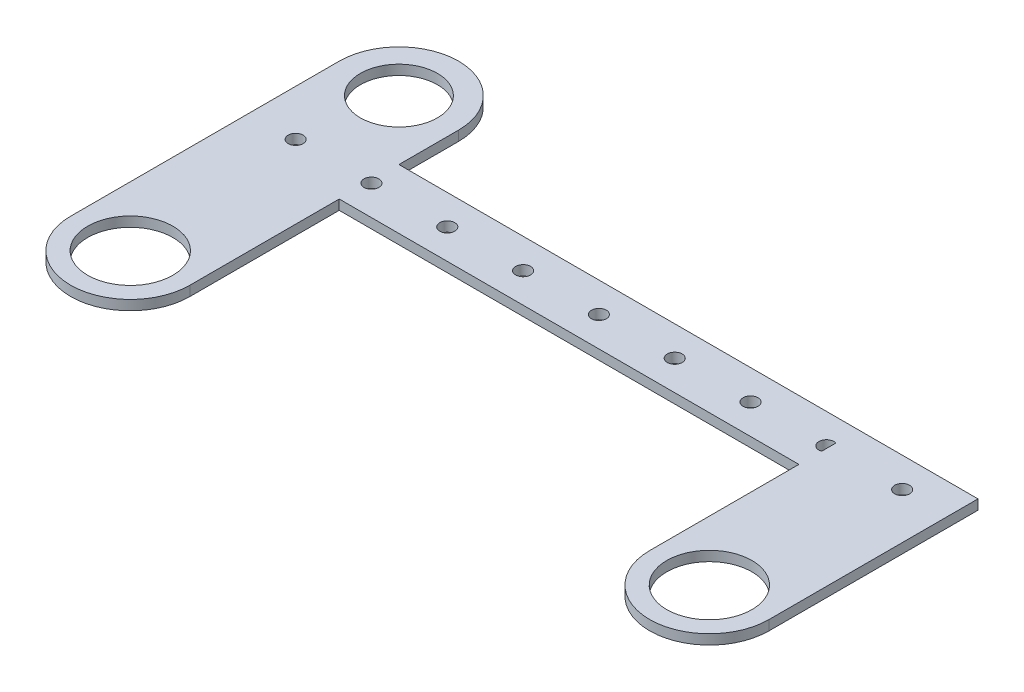
from build123d import *

# Parameters (mm, degrees)
SKETCH1_R               = 2.5
SKETCH1_R_2             = 14.26
BOSS_EXTRUDE1_DEPTH     = 3.3
SKETCH1_3_R             = 12.91
SALIENTE_EXTRUIR1_DEPTH = 3.3


with BuildPart() as part:
    # Sketch1 → Boss-Extrude1 (new body)
    with BuildSketch(Plane(origin=(0, 0, 0), x_dir=(1, 0, 0), z_dir=(0, 1, 0))):
        with BuildLine():
            Line((-117, 10), (-117, -60))
            ThreePointArc((-117, -60), (-97, -80), (-77, -60))
            Line((-77, -60), (-77, -10))
            Line((-77, -10), (77, -10))
            Line((77, -10), (77, -60))
            ThreePointArc((77, -60), (97, -80), (117, -60))
            Line((117, -60), (117, 10))
            Line((117, 10), (-117, 10))
        make_face()
        with BuildLine():
            ThreePointArc((77, -2.368543856), (73.7, 0), (77, 2.368543856))
            Line((77, 2.368543856), (77, -2.368543856))
        make_face(mode=Mode.SUBTRACT)
        with Locations((-101.6, 0)):
            Circle(SKETCH1_R, mode=Mode.SUBTRACT)
        with Locations((-76.2, 0)):
            Circle(SKETCH1_R, mode=Mode.SUBTRACT)
        with Locations((-50.8, 0)):
            Circle(SKETCH1_R, mode=Mode.SUBTRACT)
        with Locations((-25.4, 0)):
            Circle(SKETCH1_R, mode=Mode.SUBTRACT)
        Circle(SKETCH1_R, mode=Mode.SUBTRACT)
        with Locations((25.4, 0)):
            Circle(SKETCH1_R, mode=Mode.SUBTRACT)
        with Locations((50.8, 0)):
            Circle(SKETCH1_R, mode=Mode.SUBTRACT)
        with Locations((-97, -60)):
            Circle(SKETCH1_R_2, mode=Mode.SUBTRACT)
        with Locations((101.6, 0)):
            Circle(SKETCH1_R, mode=Mode.SUBTRACT)
        with Locations((97, -60)):
            Circle(SKETCH1_R_2, mode=Mode.SUBTRACT)
    extrude(amount=BOSS_EXTRUDE1_DEPTH)

    # Sketch1_3 → Saliente-Extruir1 (add)
    with BuildSketch(Plane(origin=(0, 0, 0), x_dir=(1, 0, 0), z_dir=(0, 1, 0))):
        with BuildLine():
            Line((-117, 30), (-117, 10))
            Line((-117, 10), (-77, 10))
            Line((-77, 10), (-77, 30))
            ThreePointArc((-77, 30), (-97, 50), (-117, 30))
        make_face()
        with Locations((-97, 30)):
            Circle(SKETCH1_3_R, mode=Mode.SUBTRACT)
    extrude(amount=SALIENTE_EXTRUIR1_DEPTH)


solid = part.part
